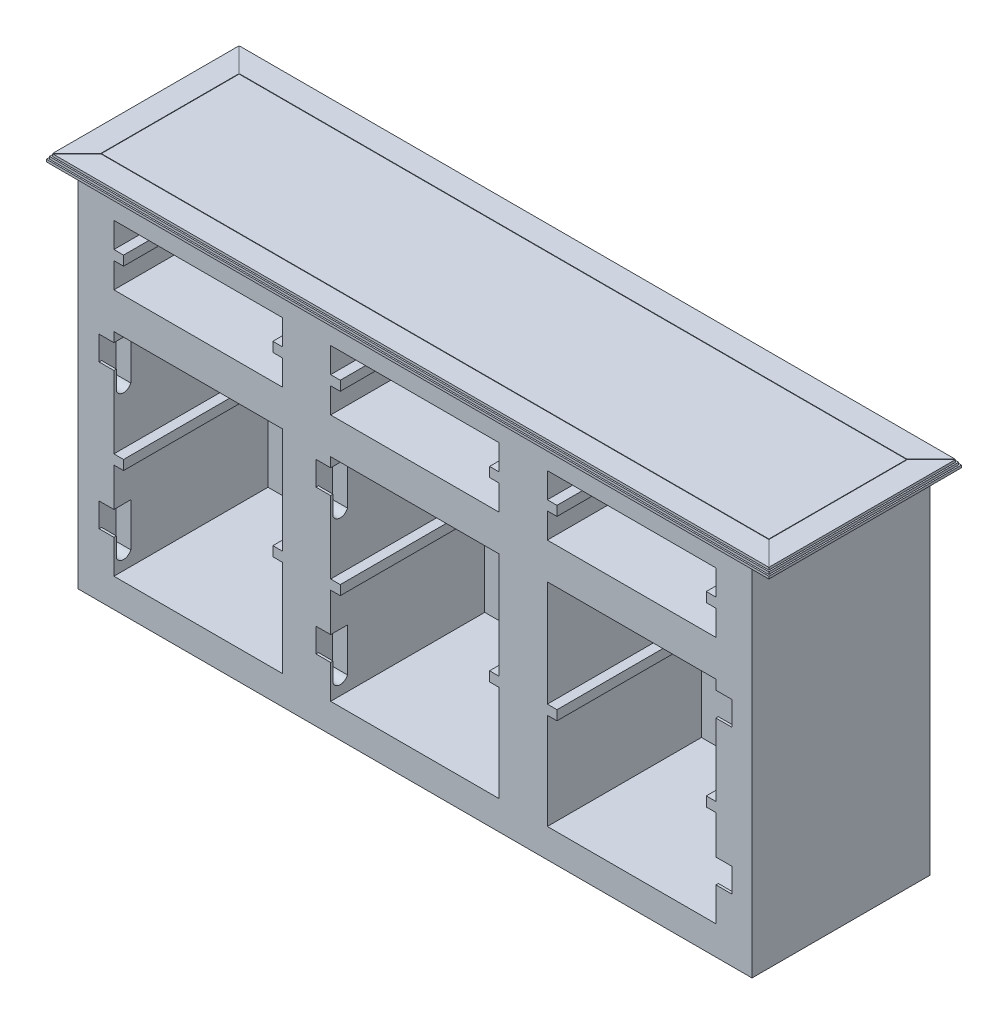
from build123d import *

# Parameters (mm, degrees)
SKETCH1_W           = 1500
SKETCH1_H           = 400
BOSS_EXTRUDE1_DEPTH = 5
SKETCH3_W           = 1494
SKETCH3_H           = 394
BOSS_EXTRUDE3_DEPTH = 5
SKETCH4_W           = 1488
SKETCH4_H           = 388
BOSS_EXTRUDE4_DEPTH = 5
SKETCH6_W           = 1386
SKETCH6_H           = 286
CUT_EXTRUDE1_DEPTH  = 1
SKETCH7_W           = 1400
SKETCH7_H           = 370
BOSS_EXTRUDE5_DEPTH = 750
CUT_EXTRUDE2_DEPTH  = 320
CUT_EXTRUDE3_DEPTH  = 30.65
CUT_EXTRUDE4_DEPTH  = 30.65
CUT_EXTRUDE6_DEPTH  = 33.56


with BuildPart() as part:
    # Sketch1 → Boss-Extrude1 (new body)
    with BuildSketch(Plane(origin=(0, 0, 0), x_dir=(1, 0, 0), z_dir=(0, 1, 0))):
        Rectangle(SKETCH1_W, SKETCH1_H)
    extrude(amount=BOSS_EXTRUDE1_DEPTH)

    # Sketch3 → Boss-Extrude3 (add)
    with BuildSketch(Plane(origin=(0, 5, 0), x_dir=(1, 0, 0), z_dir=(0, 1, 0))):
        Rectangle(SKETCH3_W, SKETCH3_H)
    extrude(amount=BOSS_EXTRUDE3_DEPTH)

    # Sketch4 → Boss-Extrude4 (add)
    with BuildSketch(Plane(origin=(0, 10, 0), x_dir=(1, 0, 0), z_dir=(0, 1, 0))):
        Rectangle(SKETCH4_W, SKETCH4_H)
    extrude(amount=BOSS_EXTRUDE4_DEPTH)

    # Sketch6 → Cut-Extrude1 (cut)
    with BuildSketch(Plane(origin=(0, 15, 0), x_dir=(1, 0, 0), z_dir=(0, 1, 0))):
        Polygon((744, 194), (743, 194), (693, 144), (-693, 144), (-743, 194), (-744, 194), (-744, 193), (-694, 143), (-694, -143), (-744, -193), (-744, -194), (-743, -194), (-693, -144), (693, -144), (743, -194), (744, -194), (744, -193), (694, -143), (694, 143), (744, 193), align=None)
        Rectangle(SKETCH6_W, SKETCH6_H, mode=Mode.SUBTRACT)
    extrude(amount=-CUT_EXTRUDE1_DEPTH, mode=Mode.SUBTRACT)

    # Sketch7 → Boss-Extrude5 (add)
    with BuildSketch(Plane.XZ):
        Rectangle(SKETCH7_W, SKETCH7_H)
    extrude(amount=BOSS_EXTRUDE5_DEPTH)

    # Sketch8 → Cut-Extrude2 (cut)
    with BuildSketch(Plane.XY.offset(185)):
        Polygon((-625, -250), (-275, -250), (-275, -470), (-295, -470), (-295, -490), (-275, -490), (-275, -690), (-625, -690), (-625, -490), (-605, -490), (-605, -470), (-625, -470), align=None)
        Polygon((-175, -250), (175, -250), (175, -470), (155, -470), (155, -490), (175, -490), (175, -690), (-175, -690), (-175, -490), (-155, -490), (-155, -470), (-175, -470), align=None)
        Polygon((275, -250), (625, -250), (625, -470), (605, -470), (605, -490), (625, -490), (625, -690), (275, -690), (275, -490), (295, -490), (295, -470), (275, -470), align=None)
        Polygon((-625, -175), (-275, -175), (-275, -122.5), (-295, -122.5), (-295, -102.5), (-275, -102.5), (-275, -50), (-625, -50), (-625, -102.5), (-605, -102.5), (-605, -122.5), (-625, -122.5), align=None)
        Polygon((-175, -175), (175, -175), (175, -122.5), (155, -122.5), (155, -102.5), (175, -102.5), (175, -50), (-175, -50), (-175, -102.5), (-155, -102.5), (-155, -122.5), (-175, -122.5), align=None)
        Polygon((275, -102.5), (275, -50), (625, -50), (625, -102.5), (605, -102.5), (605, -122.5), (625, -122.5), (625, -175), (275, -175), (275, -122.5), (295, -122.5), (295, -102.5), align=None)
    extrude(amount=-CUT_EXTRUDE2_DEPTH, mode=Mode.SUBTRACT)

    # Sketch9 → Cut-Extrude3 (cut)
    with BuildSketch(Plane(origin=(-625, 0, 0), x_dir=(0, 0, -1), z_dir=(1, 0, 0))):
        with BuildLine():
            Line((-150, -270), (-150, -360))
            ThreePointArc((-150, -360), (-165, -370), (-180, -360))
            Line((-180, -360), (-180, -320))
            Line((-180, -320), (-185, -320))
            Line((-185, -320), (-185, -270))
            Line((-185, -270), (-150, -270))
        make_face()
        with BuildLine():
            Line((-150, -570), (-150, -660))
            ThreePointArc((-150, -660), (-165, -670), (-180, -660))
            Line((-180, -660), (-180, -620))
            Line((-180, -620), (-185, -620))
            Line((-185, -620), (-185, -570))
            Line((-185, -570), (-150, -570))
        make_face()
    extrude(amount=-CUT_EXTRUDE3_DEPTH, mode=Mode.SUBTRACT)

    # Sketch10 → Cut-Extrude4 (cut)
    with BuildSketch(Plane(origin=(-175, 0, 0), x_dir=(0, 0, -1), z_dir=(1, 0, 0))):
        with BuildLine():
            Line((-150, -270), (-150, -360))
            ThreePointArc((-150, -360), (-165, -370), (-180, -360))
            Line((-180, -360), (-180, -320))
            Line((-180, -320), (-185, -320))
            Line((-185, -320), (-185, -270))
            Line((-185, -270), (-150, -270))
        make_face()
        with BuildLine():
            Line((-150, -570), (-150, -660))
            ThreePointArc((-150, -660), (-165, -670), (-180, -660))
            Line((-180, -660), (-180, -620))
            Line((-180, -620), (-185, -620))
            Line((-185, -620), (-185, -570))
            Line((-185, -570), (-150, -570))
        make_face()
    extrude(amount=-CUT_EXTRUDE4_DEPTH, mode=Mode.SUBTRACT)

    # Sketch12 → Cut-Extrude6 (cut)
    with BuildSketch(Plane.ZY.offset(-625)):
        with BuildLine():
            Line((150, -270), (150, -360))
            ThreePointArc((150, -360), (165, -370), (180, -360))
            Line((180, -360), (180, -320))
            Line((180, -320), (185, -320))
            Line((185, -320), (185, -270))
            Line((185, -270), (150, -270))
        make_face()
        with BuildLine():
            Line((150, -570), (150, -660))
            ThreePointArc((150, -660), (165, -670), (180, -660))
            Line((180, -660), (180, -620))
            Line((180, -620), (185, -620))
            Line((185, -620), (185, -570))
            Line((185, -570), (150, -570))
        make_face()
    extrude(amount=-CUT_EXTRUDE6_DEPTH, mode=Mode.SUBTRACT)


solid = part.part
